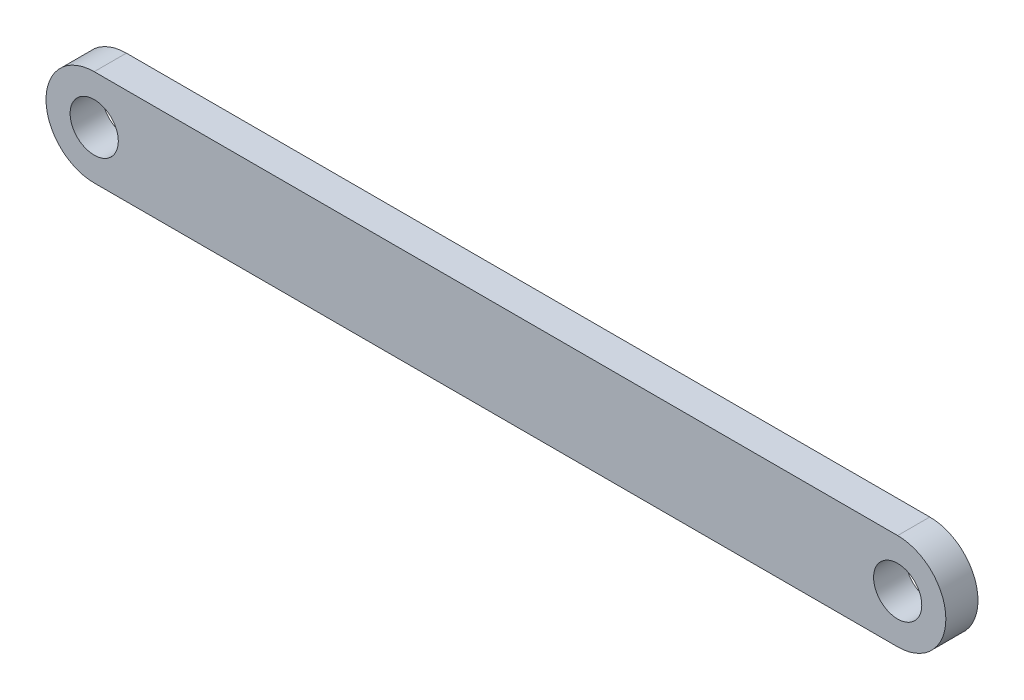
from build123d import *

# Parameters (mm, degrees)
SKETCH1_R           = 1.5
BOSS_EXTRUDE1_DEPTH = 2


with BuildPart() as part:
    # Sketch1 → Boss-Extrude1 (new body)
    with BuildSketch(Plane.XY):
        with BuildLine():
            Line((-25, 3), (25, 3))
            ThreePointArc((25, 3), (28, 0), (25, -3))
            Line((25, -3), (-25, -3))
            ThreePointArc((-25, -3), (-28, 0), (-25, 3))
        make_face()
        with Locations((-25, 0)):
            Circle(SKETCH1_R, mode=Mode.SUBTRACT)
        with Locations((25, 0)):
            Circle(SKETCH1_R, mode=Mode.SUBTRACT)
    extrude(amount=BOSS_EXTRUDE1_DEPTH)


solid = part.part
